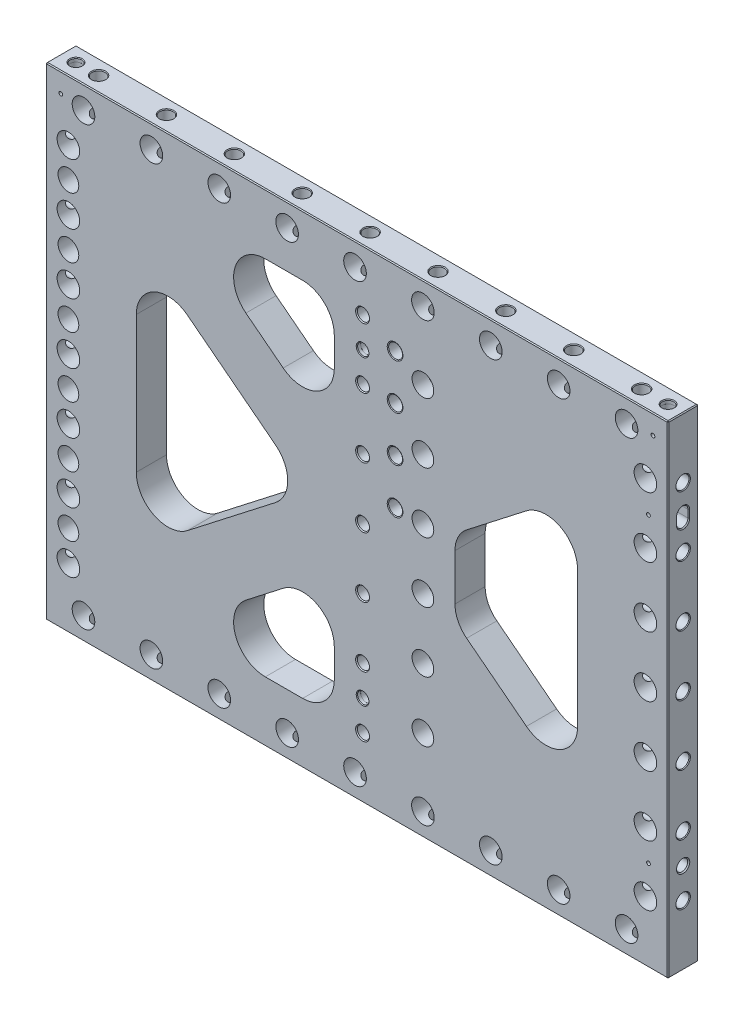
from build123d import *

# Parameters (mm, degrees)
SKETCH2_W                                  = 523.875
SKETCH2_H                                  = 406.4
EXTRUDE1_DEPTH                             = 12.7
TRIANGLES_CUT_EXTRUDE2_DEPTH               = 26.4
TRIANGLES_FILLET1_R                        = 26.67
SKETCH14_W                                 = 38.1
SKETCH14_H                                 = 406.4
EXTRUDE3_DEPTH                             = 25.4
FILLET1_R                                  = 26.67
F_3_4_0_75_DIAMETER_HOLE1_D                = 19.05
LPATTERN3_COUNT                            = 4
LPATTERN3_PITCH                            = 50.8
LPATTERN3_COL_COUNT                        = 4
LPATTERN3_COL_PITCH                        = 50.8
MIRROR1_COPY_1_D                           = 19.05
MIRROR1_COPY_2_D                           = 19.05
MIRROR1_COPY_3_D                           = 19.05
MIRROR1_COPY_7_D                           = 19.05
MIRROR1_COPY_8_D                           = 19.05
MIRROR1_COPY_9_D                           = 19.05
F_3_4_0_75_DIAMETER_HOLE2_D                = 19.05
LPATTERN4_COUNT                            = 5
LPATTERN4_PITCH                            = 57.15
LPATTERN4_COL_COUNT                        = 5
LPATTERN4_COL_PITCH                        = 57.15
MIRROR2_COPY_1_D                           = 19.05
MIRROR2_COPY_2_D                           = 19.05
MIRROR2_COPY_3_D                           = 19.05
MIRROR2_COPY_4_D                           = 19.05
MIRROR2_COPY_9_D                           = 19.05
MIRROR2_COPY_10_D                          = 19.05
MIRROR2_COPY_11_D                          = 19.05
MIRROR2_COPY_12_D                          = 19.05
MIRROR2_COPY_17_D                          = 19.05
LPATTERN5_COUNT                            = 4
LPATTERN5_PITCH                            = 50.8
LPATTERN5_COL_COUNT                        = 4
LPATTERN5_COL_PITCH                        = 50.8
LPATTERN7_COUNT                            = 6
LPATTERN7_PITCH                            = 50.8
EXTRUDE4_DEPTH                             = 25.4
FILLET2_R                                  = 25.4
F_3_8_16_TAPPED_HELI_COIL_HOLE1_AT_2_COUNT = 2
F_3_8_16_TAPPED_HELI_COIL_HOLE1_AT_2_PITCH = 38.1
F_3_8_16_TAPPED_HELI_COIL_HOLE1_AT_3_COUNT = 2
F_3_8_16_TAPPED_HELI_COIL_HOLE1_AT_3_PITCH = 76.2
F_3_8_16_TAPPED_HELI_COIL_HOLE1_AT_4_COUNT = 2
F_3_8_16_TAPPED_HELI_COIL_HOLE1_AT_4_PITCH = 114.3
LPATTERN6_COUNT                            = 6
LPATTERN6_PITCH                            = 50.8
F_3_8_0_376_PIN_LOCATE1_D                  = 9.5504
F_3_8_0_376_PIN_LOCATE1_DEPTH              = 19.05
F_3_8_0_376_PIN_LOCATE1_CSINK_D            = 11.176
F_3_8_0_376_PIN_LOCATE1_CSINK_ANGLE        = 82
F_3_8_0_376_PIN_LOCATE1_TIP                = 2.869229628
SLOT_LOCATE1_DEPTH                         = 19.05
CHAMFER1_SIZE                              = 0.762
F_3_8_0_375_PIN_LEAD_IN_HOLE1_AT_2_COUNT   = 2
F_3_8_0_375_PIN_LEAD_IN_HOLE1_AT_2_PITCH   = 498.475
F_1_8_0_125_DIAMETER_HOLE1_D               = 3.175
F_1_8_0_125_DIAMETER_HOLE1_DEPTH           = 9.652
F_1_8_0_125_DIAMETER_HOLE1_TIP             = 0.953866233
F_3_8_0_375_PIN_LEAD_IN_HOLE2_AT_2_COUNT   = 2
F_3_8_0_375_PIN_LEAD_IN_HOLE2_AT_2_PITCH   = 254
CHAMFER2_SIZE                              = 0.762


with BuildPart() as part:
    # Sketch2 → Extrude1 (new body, symmetric)
    with BuildSketch(Plane.XY):
        Rectangle(SKETCH2_W, SKETCH2_H)
    extrude(amount=EXTRUDE1_DEPTH, both=True)

    # Sketch8 → Triangles -- Cut-Extrude2 (cut, through all)
    with BuildSketch(Plane.XY.offset(12.7)):
        Polygon((-185.7375, 111.940466206), (-41.439242781, 0), (-185.7375, -111.940466206), align=None)
        Polygon((-155.013882219, 152.4), (0, 32.146806521), (155.013882219, 152.4), align=None)
        Polygon((185.7375, 111.940466206), (185.7375, -111.940466206), (41.439242781, 0), align=None)
        Polygon((0, -32.146806521), (-155.013882219, -152.4), (155.013882219, -152.4), align=None)
    extrude(amount=-TRIANGLES_CUT_EXTRUDE2_DEPTH, mode=Mode.SUBTRACT)

    # Triangles -- Fillet1
    triangles_fillet1_edges = [part.edges().sort_by_distance(p)[0] for p in [
        (-185.7375, -111.940466206, 0),
        (-185.7375, 111.940466206, 0),
        (-41.439242781, 0, 0),
        (-155.013882219, 152.4, 0),
        (155.013882219, 152.4, 0),
        (0, 32.146806521, 0),
        (41.439242781, 0, 0),
        (185.7375, 111.940466206, 0),
        (185.7375, -111.940466206, 0),
        (0, -32.146806521, 0),
        (155.013882219, -152.4, 0),
        (-155.013882219, -152.4, 0),
    ]]
    fillet(triangles_fillet1_edges, radius=TRIANGLES_FILLET1_R)

    # Sketch14 → Extrude3 (add, through all)
    with BuildSketch(Plane.XY.offset(12.7)):
        Rectangle(SKETCH14_W, SKETCH14_H)
    extrude(amount=-EXTRUDE3_DEPTH)

    # Fillet1
    fillet1_edges = [part.edges().sort_by_distance(p)[0] for p in [
        (-19.05, -46.924988339, 0),
        (19.05, -152.4, 0),
        (19.05, 152.4, 0),
        (19.05, 46.924988339, 0),
        (19.05, -46.924988339, 0),
        (-19.05, 152.4, 0),
        (-19.05, -152.4, 0),
        (-19.05, 46.924988339, 0),
    ]]
    fillet(fillet1_edges, radius=FILLET1_R)

    # 3/4 (0.75) Diameter Hole1 (through all)
    with Locations(Plane.XY.offset(12.7)):
        with Locations((-242.8875, 0)):
            f_3_4_0_75_diameter_hole1 = Hole(F_3_4_0_75_DIAMETER_HOLE1_D / 2)

    # Sketch5 → 7/16 (0.4375) Diameter Hole1 (revolve, cut)
    with BuildSketch(Plane(origin=(-261.9375, 0, 0), x_dir=(0, 0, 1), z_dir=(0, 1, 0))):
        Polygon((0, 0), (0, 38.263531814), (5.55625, 34.925), (5.55625, 0.620911348), (6.096, 0), align=None)
    f_7_16_0_4375_diameter_hole1 = revolve(axis=Axis((-268.2875, 0, 0), (1, 0, 0)), mode=Mode.SUBTRACT)

    # LPattern3: 3/4 (0.75) Diameter Hole1, 7/16 (0.4375) Diameter Hole1 ×4
    with Locations(*[(0, i * LPATTERN3_PITCH, 0) for i in range(1, LPATTERN3_COUNT)]):
        add(f_3_4_0_75_diameter_hole1, mode=Mode.SUBTRACT)
        add(f_7_16_0_4375_diameter_hole1, mode=Mode.SUBTRACT)

    # LPattern3 col: 3/4 (0.75) Diameter Hole1, 7/16 (0.4375) Diameter Hole1 ×4
    with Locations(*[(0, -i * LPATTERN3_COL_PITCH, 0) for i in range(1, LPATTERN3_COL_COUNT)]):
        add(f_3_4_0_75_diameter_hole1, mode=Mode.SUBTRACT)
        add(f_7_16_0_4375_diameter_hole1, mode=Mode.SUBTRACT)

    # Mirror1: 3/4 (0.75) Diameter Hole1, 7/16 (0.4375) Diameter Hole1 across plane
    add(f_3_4_0_75_diameter_hole1.mirror(Plane(origin=(0, 0, 0), x_dir=(0, 0, 1), z_dir=(1, 0, 0))), mode=Mode.SUBTRACT)
    add(f_7_16_0_4375_diameter_hole1.mirror(Plane(origin=(0, 0, 0), x_dir=(0, 0, 1), z_dir=(1, 0, 0))), mode=Mode.SUBTRACT)

    # Mirror1 copy 1 (through all)
    with Locations(Plane(origin=(0, 50.8, 12.7), x_dir=(-1, 0, 0), z_dir=(0, 0, 1))):
        with Locations((-242.8875, 0)):
            Hole(MIRROR1_COPY_1_D / 2)

    # Mirror1 copy 2 (through all)
    with Locations(Plane(origin=(0, 101.6, 12.7), x_dir=(-1, 0, 0), z_dir=(0, 0, 1))):
        with Locations((-242.8875, 0)):
            Hole(MIRROR1_COPY_2_D / 2)

    # Mirror1 copy 3 (through all)
    with Locations(Plane(origin=(0, 152.4, 12.7), x_dir=(-1, 0, 0), z_dir=(0, 0, 1))):
        with Locations((-242.8875, 0)):
            Hole(MIRROR1_COPY_3_D / 2)

    # Mirror1 copy 4 sketch → Mirror1 copy 4 (revolve, cut)
    with BuildSketch(Plane(origin=(261.9375, 50.8, 0), x_dir=(0, 0, 1), z_dir=(0, 1, 0))):
        Polygon((0, 0), (0, -38.263531814), (5.55625, -34.925), (5.55625, -0.620911348), (6.096, 0), align=None)
    revolve(axis=Axis((268.2875, 50.8, 0), (1, 0, 0)), mode=Mode.SUBTRACT)

    # Mirror1 copy 5 sketch → Mirror1 copy 5 (revolve, cut)
    with BuildSketch(Plane(origin=(261.9375, 101.6, 0), x_dir=(0, 0, 1), z_dir=(0, 1, 0))):
        Polygon((0, 0), (0, -38.263531814), (5.55625, -34.925), (5.55625, -0.620911348), (6.096, 0), align=None)
    revolve(axis=Axis((268.2875, 101.6, 0), (1, 0, 0)), mode=Mode.SUBTRACT)

    # Mirror1 copy 6 sketch → Mirror1 copy 6 (revolve, cut)
    with BuildSketch(Plane(origin=(261.9375, 152.4, 0), x_dir=(0, 0, 1), z_dir=(0, 1, 0))):
        Polygon((0, 0), (0, -38.263531814), (5.55625, -34.925), (5.55625, -0.620911348), (6.096, 0), align=None)
    revolve(axis=Axis((268.2875, 152.4, 0), (1, 0, 0)), mode=Mode.SUBTRACT)

    # Mirror1 copy 7 (through all)
    with Locations(Plane(origin=(0, -50.8, 12.7), x_dir=(-1, 0, 0), z_dir=(0, 0, 1))):
        with Locations((-242.8875, 0)):
            Hole(MIRROR1_COPY_7_D / 2)

    # Mirror1 copy 8 (through all)
    with Locations(Plane(origin=(0, -101.6, 12.7), x_dir=(-1, 0, 0), z_dir=(0, 0, 1))):
        with Locations((-242.8875, 0)):
            Hole(MIRROR1_COPY_8_D / 2)

    # Mirror1 copy 9 (through all)
    with Locations(Plane(origin=(0, -152.4, 12.7), x_dir=(-1, 0, 0), z_dir=(0, 0, 1))):
        with Locations((-242.8875, 0)):
            Hole(MIRROR1_COPY_9_D / 2)

    # Mirror1 copy 10 sketch → Mirror1 copy 10 (revolve, cut)
    with BuildSketch(Plane(origin=(261.9375, -50.8, 0), x_dir=(0, 0, 1), z_dir=(0, 1, 0))):
        Polygon((0, 0), (0, -38.263531814), (5.55625, -34.925), (5.55625, -0.620911348), (6.096, 0), align=None)
    revolve(axis=Axis((268.2875, -50.8, 0), (1, 0, 0)), mode=Mode.SUBTRACT)

    # Mirror1 copy 11 sketch → Mirror1 copy 11 (revolve, cut)
    with BuildSketch(Plane(origin=(261.9375, -101.6, 0), x_dir=(0, 0, 1), z_dir=(0, 1, 0))):
        Polygon((0, 0), (0, -38.263531814), (5.55625, -34.925), (5.55625, -0.620911348), (6.096, 0), align=None)
    revolve(axis=Axis((268.2875, -101.6, 0), (1, 0, 0)), mode=Mode.SUBTRACT)

    # Mirror1 copy 12 sketch → Mirror1 copy 12 (revolve, cut)
    with BuildSketch(Plane(origin=(261.9375, -152.4, 0), x_dir=(0, 0, 1), z_dir=(0, 1, 0))):
        Polygon((0, 0), (0, -38.263531814), (5.55625, -34.925), (5.55625, -0.620911348), (6.096, 0), align=None)
    revolve(axis=Axis((268.2875, -152.4, 0), (1, 0, 0)), mode=Mode.SUBTRACT)

    # 3/4 (0.75) Diameter Hole2 (through all)
    with Locations(Plane.XY.offset(12.7)):
        with Locations((-1.5875, -184.15)):
            f_3_4_0_75_diameter_hole2 = Hole(F_3_4_0_75_DIAMETER_HOLE2_D / 2)

    # Sketch12 → 7/16 (0.4375) Diameter Hole2 (revolve, cut)
    with BuildSketch(Plane(origin=(-1.5875, -203.2, 0), x_dir=(0, 0, -1), z_dir=(1, 0, 0))):
        Polygon((0, 0), (0, 38.263531814), (5.55625, 34.925), (5.55625, 0.620911348), (6.096, 0), align=None)
    f_7_16_0_4375_diameter_hole2 = revolve(axis=Axis((-1.5875, -209.55, 0), (0, 1, 0)), mode=Mode.SUBTRACT)

    # LPattern4: 3/4 (0.75) Diameter Hole2, 7/16 (0.4375) Diameter Hole2 ×5
    with Locations(*[(i * LPATTERN4_PITCH, 0, 0) for i in range(1, LPATTERN4_COUNT)]):
        add(f_3_4_0_75_diameter_hole2, mode=Mode.SUBTRACT)
        add(f_7_16_0_4375_diameter_hole2, mode=Mode.SUBTRACT)

    # LPattern4 col: 3/4 (0.75) Diameter Hole2, 7/16 (0.4375) Diameter Hole2 ×5
    with Locations(*[(-i * LPATTERN4_COL_PITCH, 0, 0) for i in range(1, LPATTERN4_COL_COUNT)]):
        add(f_3_4_0_75_diameter_hole2, mode=Mode.SUBTRACT)
        add(f_7_16_0_4375_diameter_hole2, mode=Mode.SUBTRACT)

    # Mirror2 copy 1 (through all)
    with Locations(Plane(origin=(57.15, 0, 12.7), x_dir=(1, 0, 0), z_dir=(0, 0, 1))):
        with Locations((-1.5875, 184.15)):
            Hole(MIRROR2_COPY_1_D / 2)

    # Mirror2 copy 2 (through all)
    with Locations(Plane(origin=(114.3, 0, 12.7), x_dir=(1, 0, 0), z_dir=(0, 0, 1))):
        with Locations((-1.5875, 184.15)):
            Hole(MIRROR2_COPY_2_D / 2)

    # Mirror2 copy 3 (through all)
    with Locations(Plane(origin=(171.45, 0, 12.7), x_dir=(1, 0, 0), z_dir=(0, 0, 1))):
        with Locations((-1.5875, 184.15)):
            Hole(MIRROR2_COPY_3_D / 2)

    # Mirror2 copy 4 (through all)
    with Locations(Plane(origin=(228.6, 0, 12.7), x_dir=(1, 0, 0), z_dir=(0, 0, 1))):
        with Locations((-1.5875, 184.15)):
            Hole(MIRROR2_COPY_4_D / 2)

    # Mirror2 copy 5 sketch → Mirror2 copy 5 (revolve, cut)
    with BuildSketch(Plane(origin=(55.5625, 203.2, 0), x_dir=(0, 0, -1), z_dir=(1, 0, 0))):
        Polygon((0, 0), (0, -38.263531814), (5.55625, -34.925), (5.55625, -0.620911348), (6.096, 0), align=None)
    revolve(axis=Axis((55.5625, 209.55, 0), (0, 1, 0)), mode=Mode.SUBTRACT)

    # Mirror2 copy 6 sketch → Mirror2 copy 6 (revolve, cut)
    with BuildSketch(Plane(origin=(112.7125, 203.2, 0), x_dir=(0, 0, -1), z_dir=(1, 0, 0))):
        Polygon((0, 0), (0, -38.263531814), (5.55625, -34.925), (5.55625, -0.620911348), (6.096, 0), align=None)
    revolve(axis=Axis((112.7125, 209.55, 0), (0, 1, 0)), mode=Mode.SUBTRACT)

    # Mirror2 copy 7 sketch → Mirror2 copy 7 (revolve, cut)
    with BuildSketch(Plane(origin=(169.8625, 203.2, 0), x_dir=(0, 0, -1), z_dir=(1, 0, 0))):
        Polygon((0, 0), (0, -38.263531814), (5.55625, -34.925), (5.55625, -0.620911348), (6.096, 0), align=None)
    revolve(axis=Axis((169.8625, 209.55, 0), (0, 1, 0)), mode=Mode.SUBTRACT)

    # Mirror2 copy 8 sketch → Mirror2 copy 8 (revolve, cut)
    with BuildSketch(Plane(origin=(227.0125, 203.2, 0), x_dir=(0, 0, -1), z_dir=(1, 0, 0))):
        Polygon((0, 0), (0, -38.263531814), (5.55625, -34.925), (5.55625, -0.620911348), (6.096, 0), align=None)
    revolve(axis=Axis((227.0125, 209.55, 0), (0, 1, 0)), mode=Mode.SUBTRACT)

    # Mirror2 copy 9 (through all)
    with Locations(Plane(origin=(-57.15, 0, 12.7), x_dir=(1, 0, 0), z_dir=(0, 0, 1))):
        with Locations((-1.5875, 184.15)):
            Hole(MIRROR2_COPY_9_D / 2)

    # Mirror2 copy 10 (through all)
    with Locations(Plane(origin=(-114.3, 0, 12.7), x_dir=(1, 0, 0), z_dir=(0, 0, 1))):
        with Locations((-1.5875, 184.15)):
            Hole(MIRROR2_COPY_10_D / 2)

    # Mirror2 copy 11 (through all)
    with Locations(Plane(origin=(-171.45, 0, 12.7), x_dir=(1, 0, 0), z_dir=(0, 0, 1))):
        with Locations((-1.5875, 184.15)):
            Hole(MIRROR2_COPY_11_D / 2)

    # Mirror2 copy 12 (through all)
    with Locations(Plane(origin=(-228.6, 0, 12.7), x_dir=(1, 0, 0), z_dir=(0, 0, 1))):
        with Locations((-1.5875, 184.15)):
            Hole(MIRROR2_COPY_12_D / 2)

    # Mirror2 copy 13 sketch → Mirror2 copy 13 (revolve, cut)
    with BuildSketch(Plane(origin=(-58.7375, 203.2, 0), x_dir=(0, 0, -1), z_dir=(1, 0, 0))):
        Polygon((0, 0), (0, -38.263531814), (5.55625, -34.925), (5.55625, -0.620911348), (6.096, 0), align=None)
    revolve(axis=Axis((-58.7375, 209.55, 0), (0, 1, 0)), mode=Mode.SUBTRACT)

    # Mirror2 copy 14 sketch → Mirror2 copy 14 (revolve, cut)
    with BuildSketch(Plane(origin=(-115.8875, 203.2, 0), x_dir=(0, 0, -1), z_dir=(1, 0, 0))):
        Polygon((0, 0), (0, -38.263531814), (5.55625, -34.925), (5.55625, -0.620911348), (6.096, 0), align=None)
    revolve(axis=Axis((-115.8875, 209.55, 0), (0, 1, 0)), mode=Mode.SUBTRACT)

    # Mirror2 copy 15 sketch → Mirror2 copy 15 (revolve, cut)
    with BuildSketch(Plane(origin=(-173.0375, 203.2, 0), x_dir=(0, 0, -1), z_dir=(1, 0, 0))):
        Polygon((0, 0), (0, -38.263531814), (5.55625, -34.925), (5.55625, -0.620911348), (6.096, 0), align=None)
    revolve(axis=Axis((-173.0375, 209.55, 0), (0, 1, 0)), mode=Mode.SUBTRACT)

    # Mirror2 copy 16 sketch → Mirror2 copy 16 (revolve, cut)
    with BuildSketch(Plane(origin=(-230.1875, 203.2, 0), x_dir=(0, 0, -1), z_dir=(1, 0, 0))):
        Polygon((0, 0), (0, -38.263531814), (5.55625, -34.925), (5.55625, -0.620911348), (6.096, 0), align=None)
    revolve(axis=Axis((-230.1875, 209.55, 0), (0, 1, 0)), mode=Mode.SUBTRACT)

    # Mirror2 copy 17 (through all)
    with Locations(Plane.XY.offset(12.7)):
        with Locations((-1.5875, 184.15)):
            Hole(MIRROR2_COPY_17_D / 2)

    # Mirror2 copy 18 sketch → Mirror2 copy 18 (revolve, cut)
    with BuildSketch(Plane(origin=(-1.5875, 203.2, 0), x_dir=(0, 0, -1), z_dir=(1, 0, 0))):
        Polygon((0, 0), (0, -38.263531814), (5.55625, -34.925), (5.55625, -0.620911348), (6.096, 0), align=None)
    revolve(axis=Axis((-1.5875, 209.55, 0), (0, 1, 0)), mode=Mode.SUBTRACT)

    # Sketch15 → CBORE for 3/8 Socket Head Cap Screw4 (revolve, cut)
    with BuildSketch(Plane(origin=(4.7625, 0, -12.7), x_dir=(0, 1, 0), z_dir=(1, 0, 0))):
        Polygon((0, 0), (0, 25.4), (5.842, 25.4), (5.15874, 24.613999282), (5.15874, 10.668), (8.73125, 10.668), (8.73125, 0), align=None)
    cbore_for_3_8_socket_head_cap_screw4 = revolve(axis=Axis((4.7625, 0, -19.05), (0, 0, 1)), mode=Mode.SUBTRACT)

    # LPattern5: CBORE for 3/8 Socket Head Cap Screw4 ×4
    with Locations(*[(0, -i * LPATTERN5_PITCH, 0) for i in range(1, LPATTERN5_COUNT)]):
        add(cbore_for_3_8_socket_head_cap_screw4, mode=Mode.SUBTRACT)

    # LPattern5 col: CBORE for 3/8 Socket Head Cap Screw4 ×4
    with Locations(*[(0, i * LPATTERN5_COL_PITCH, 0) for i in range(1, LPATTERN5_COL_COUNT)]):
        add(cbore_for_3_8_socket_head_cap_screw4, mode=Mode.SUBTRACT)

    # Sketch17 → CBORE for 3/8 Socket Head Cap Screw1 (revolve, cut)
    with BuildSketch(Plane(origin=(-242.8875, -127, 12.7), x_dir=(0, -1, 0), z_dir=(1, 0, 0))):
        Polygon((0, 0), (0, 25.4), (5.842, 25.4), (5.15874, 24.613999282), (5.15874, 12.7), (8.73125, 12.7), (8.73125, 0), align=None)
    cbore_for_3_8_socket_head_cap_screw1 = revolve(axis=Axis((-242.8875, -127, 19.05), (0, 0, -1)), mode=Mode.SUBTRACT)

    # LPattern7: CBORE for 3/8 Socket Head Cap Screw1 ×6
    with Locations(*[(0, i * LPATTERN7_PITCH, 0) for i in range(1, LPATTERN7_COUNT)]):
        add(cbore_for_3_8_socket_head_cap_screw1, mode=Mode.SUBTRACT)

    # Sketch19 → Extrude4 (add, through all)
    with BuildSketch(Plane.XY.offset(12.7)):
        with BuildLine():
            Line((82.55, 96.1855944), (93.470638591, 104.657362519))
            ThreePointArc((93.470638591, 104.657362519), (102.355266417, 134.369492415), (77.123380423, 152.4))
            Line((77.123380423, 152.4), (45.72, 152.4))
            ThreePointArc((45.72, 152.4), (26.861462146, 144.588537854), (19.05, 125.73))
            Line((19.05, 125.73), (19.05, 101.368589732))
            Line((19.05, 101.368589732), (19.05, -101.368589732))
            Line((19.05, -101.368589732), (19.05, -125.73))
            ThreePointArc((19.05, -125.73), (26.861462146, -144.588537854), (45.72, -152.4))
            Line((45.72, -152.4), (77.123380423, -152.4))
            ThreePointArc((77.123380423, -152.4), (102.355266417, -134.369492415), (93.470638591, -104.657362519))
            Line((93.470638591, -104.657362519), (82.55, -96.1855944))
            Line((82.55, -96.1855944), (82.55, 96.1855944))
        make_face()
    extrude(amount=-EXTRUDE4_DEPTH)

    # Fillet2
    fillet2_edges = [part.edges().sort_by_distance(p)[0] for p in [
        (82.55, 31.891981358, 0),
        (82.55, -31.891981358, 0),
    ]]
    fillet(fillet2_edges, radius=FILLET2_R)

    # Sketch22 → 3/8-16 Tapped Heli-Coil Hole1 (revolve, cut)
    with BuildSketch(Plane(origin=(32.128968, 25.4, 12.7), x_dir=(0, -1, 0), z_dir=(1, 0, 0))):
        Polygon((0, 0), (0, 25.4), (6.604, 25.4), (5.0419, 24.498121144), (5.0419, 22.86), (5.84454, 22.86), (5.84454, 0.438474435), (6.604, 0), align=None)
    f_3_8_16_tapped_heli_coil_hole1 = revolve(axis=Axis((32.128968, 25.4, 19.05), (0, 0, -1)), mode=Mode.SUBTRACT)

    # 3/8-16 Tapped Heli-Coil Hole1 at 2: 3/8-16 Tapped Heli-Coil Hole1 ×2
    with Locations(*[(0, i * F_3_8_16_TAPPED_HELI_COIL_HOLE1_AT_2_PITCH, 0) for i in range(1, F_3_8_16_TAPPED_HELI_COIL_HOLE1_AT_2_COUNT)]):
        add(f_3_8_16_tapped_heli_coil_hole1, mode=Mode.SUBTRACT)

    # 3/8-16 Tapped Heli-Coil Hole1 at 3: 3/8-16 Tapped Heli-Coil Hole1 ×2
    with Locations(*[(0, i * F_3_8_16_TAPPED_HELI_COIL_HOLE1_AT_3_PITCH, 0) for i in range(1, F_3_8_16_TAPPED_HELI_COIL_HOLE1_AT_3_COUNT)]):
        add(f_3_8_16_tapped_heli_coil_hole1, mode=Mode.SUBTRACT)

    # 3/8-16 Tapped Heli-Coil Hole1 at 4: 3/8-16 Tapped Heli-Coil Hole1 ×2
    with Locations(*[(0, i * F_3_8_16_TAPPED_HELI_COIL_HOLE1_AT_4_PITCH, 0) for i in range(1, F_3_8_16_TAPPED_HELI_COIL_HOLE1_AT_4_COUNT)]):
        add(f_3_8_16_tapped_heli_coil_hole1, mode=Mode.SUBTRACT)

    # Sketch24 → CBORE for 3/8 Socket Head Cap Screw3 (revolve, cut)
    with BuildSketch(Plane(origin=(55.5625, -127, 12.7), x_dir=(0, -1, 0), z_dir=(1, 0, 0))):
        Polygon((0, 0), (0, 25.4), (6.35, 25.4), (5.55625, 24.486895077), (5.55625, 12.7), (9.128125, 12.7), (9.128125, 0), align=None)
    cbore_for_3_8_socket_head_cap_screw3 = revolve(axis=Axis((55.5625, -127, 19.05), (0, 0, -1)), mode=Mode.SUBTRACT)

    # LPattern6: CBORE for 3/8 Socket Head Cap Screw3 ×6
    with Locations(*[(0, i * LPATTERN6_PITCH, 0) for i in range(1, LPATTERN6_COUNT)]):
        add(cbore_for_3_8_socket_head_cap_screw3, mode=Mode.SUBTRACT)

    # 3/8 (0.376) Pin Locate1
    with Locations(Plane(origin=(261.9375, 0, 0), x_dir=(0, 0, -1), z_dir=(1, 0, 0))):
        with Locations((0, -127)):
            CounterSinkHole(F_3_8_0_376_PIN_LOCATE1_D / 2, F_3_8_0_376_PIN_LOCATE1_CSINK_D / 2, depth=F_3_8_0_376_PIN_LOCATE1_DEPTH, counter_sink_angle=F_3_8_0_376_PIN_LOCATE1_CSINK_ANGLE)
            with Locations((0, 0, -(F_3_8_0_376_PIN_LOCATE1_DEPTH + F_3_8_0_376_PIN_LOCATE1_TIP / 2))):  # 118° drill point
                Cone(0, F_3_8_0_376_PIN_LOCATE1_D / 2, F_3_8_0_376_PIN_LOCATE1_TIP, mode=Mode.SUBTRACT)

    # Sketch28 → Slot Locate1 (cut)
    with BuildSketch(Plane(origin=(261.9375, 0, 0), x_dir=(0, 0, -1), z_dir=(1, 0, 0))):
        with BuildLine():
            Line((4.7752, 123.825), (4.7752, 130.175))
            ThreePointArc((4.7752, 130.175), (0, 134.9502), (-4.7752, 130.175))
            Line((-4.7752, 130.175), (-4.7752, 123.825))
            ThreePointArc((-4.7752, 123.825), (0, 119.0498), (4.7752, 123.825))
        make_face()
    extrude(amount=-SLOT_LOCATE1_DEPTH, mode=Mode.SUBTRACT)

    # Chamfer1
    chamfer1_edges = [part.edges().sort_by_distance(p)[0] for p in [
        (261.9375, 119.0498, 0),
        (261.9375, 127, -4.7752),
        (261.9375, 134.9502, 0),
        (261.9375, 127, 4.7752),
    ]]
    chamfer(chamfer1_edges, length=CHAMFER1_SIZE)

    # Sketch29 → 3/8 (0.375) Pin + Lead-In Hole1 (revolve, cut)
    with BuildSketch(Plane(origin=(249.2375, 203.2, 0), x_dir=(0, 0, 1), z_dir=(1, 0, 0))):
        Polygon((0, 0), (0, 21.911598698), (4.7625, 19.05), (4.7625, 3.175), (4.7879, 3.175), (4.7879, 0.628216187), (5.334, 0), align=None)
    f_3_8_0_375_pin_lead_in_hole1 = revolve(axis=Axis((249.2375, 209.55, 0), (0, -1, 0)), mode=Mode.SUBTRACT)

    # 3/8 (0.375) Pin + Lead-In Hole1 at 2: 3/8 (0.375) Pin + Lead-In Hole1 ×2
    with Locations(*[(-i * F_3_8_0_375_PIN_LEAD_IN_HOLE1_AT_2_PITCH, 0, 0) for i in range(1, F_3_8_0_375_PIN_LEAD_IN_HOLE1_AT_2_COUNT)]):
        add(f_3_8_0_375_pin_lead_in_hole1, mode=Mode.SUBTRACT)

    # 1/8 (0.125) Diameter Hole1
    with Locations(Plane.XY.offset(12.7)):
        with Locations((-249.2375, 186.69), (249.2375, 186.69), (245.4275, 127), (245.4275, -127)):
            Hole(F_1_8_0_125_DIAMETER_HOLE1_D / 2, depth=F_1_8_0_125_DIAMETER_HOLE1_DEPTH)
            with Locations((0, 0, -(F_1_8_0_125_DIAMETER_HOLE1_DEPTH + F_1_8_0_125_DIAMETER_HOLE1_TIP / 2))):  # 118° drill point
                Cone(0, F_1_8_0_125_DIAMETER_HOLE1_D / 2, F_1_8_0_125_DIAMETER_HOLE1_TIP, mode=Mode.SUBTRACT)

    # Sketch33 → 3/8 (0.375) Pin + Lead-In Hole2 (revolve, cut)
    with BuildSketch(Plane(origin=(4.7625, 127, 12.7), x_dir=(0, -1, 0), z_dir=(1, 0, 0))):
        Polygon((0, 0), (0, 25.4), (4.7625, 25.4), (4.7625, 3.175), (4.7879, 3.175), (4.7879, 0.628216187), (5.334, 0), align=None)
    f_3_8_0_375_pin_lead_in_hole2 = revolve(axis=Axis((4.7625, 127, 19.05), (0, 0, -1)), mode=Mode.SUBTRACT)

    # 3/8 (0.375) Pin + Lead-In Hole2 at 2: 3/8 (0.375) Pin + Lead-In Hole2 ×2
    with Locations(*[(0, -i * F_3_8_0_375_PIN_LEAD_IN_HOLE2_AT_2_PITCH, 0) for i in range(1, F_3_8_0_375_PIN_LEAD_IN_HOLE2_AT_2_COUNT)]):
        add(f_3_8_0_375_pin_lead_in_hole2, mode=Mode.SUBTRACT)

    # Chamfer2
    chamfer2_edges = [part.edges().sort_by_distance(p)[0] for p in [
        (261.9375, 0, 12.7),
        (0, 203.2, 12.7),
        (-261.9375, 0, 12.7),
        (0, 203.2, -12.7),
        (261.9375, 0, -12.7),
        (0, -203.2, -12.7),
        (-261.9375, 0, -12.7),
        (0, -203.2, 12.7),
        (-261.9375, 203.2, 0),
        (261.9375, 203.2, 0),
        (261.9375, -203.2, 0),
        (-261.9375, -203.2, 0),
    ]]
    chamfer(chamfer2_edges, length=CHAMFER2_SIZE)


solid = part.part
